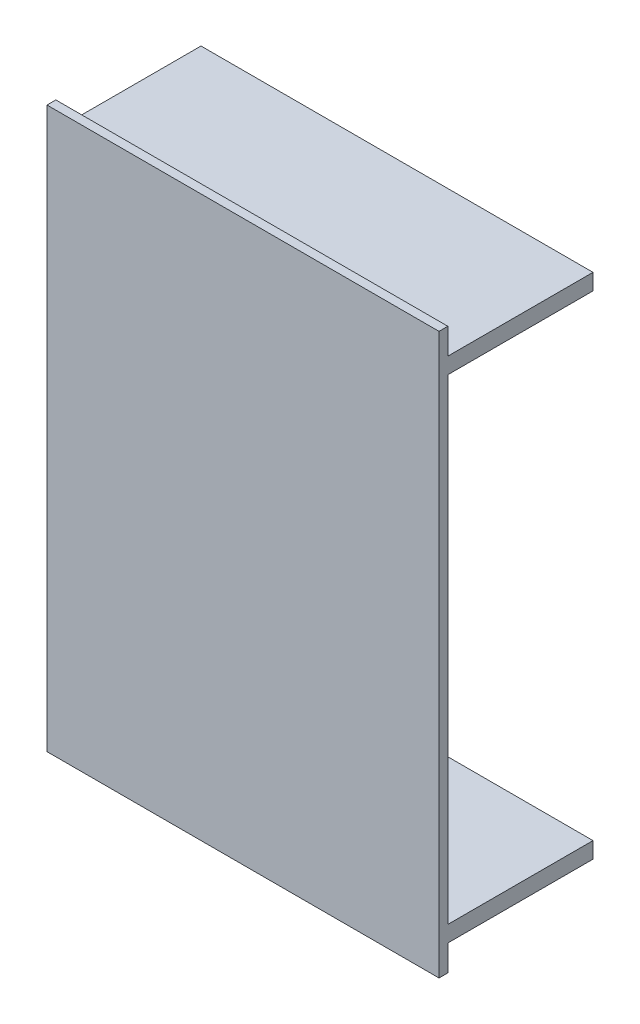
from build123d import *

# Parameters (mm, degrees)
SKETCH1_W           = 280
SKETCH1_H           = 400
BOSS_EXTRUDE1_DEPTH = 6.3
SKETCH4_W           = 103.7
SKETCH4_H           = 11.5
BOSS_EXTRUDE2_DEPTH = 280


with BuildPart() as part:
    # Sketch1 → Boss-Extrude1 (new body)
    with BuildSketch(Plane.XY):
        with Locations((140, 200)):
            Rectangle(SKETCH1_W, SKETCH1_H)
    extrude(amount=BOSS_EXTRUDE1_DEPTH)

    # Sketch4 → Boss-Extrude2 (add)
    with BuildSketch(Plane(origin=(0, 0, 0), x_dir=(0, 0, -1), z_dir=(1, 0, 0))):
        with Locations((51.85, 24.25)):
            Rectangle(SKETCH4_W, SKETCH4_H)
        with Locations((51.85, 375.75)):
            Rectangle(SKETCH4_W, SKETCH4_H)
    extrude(amount=BOSS_EXTRUDE2_DEPTH)


solid = part.part
